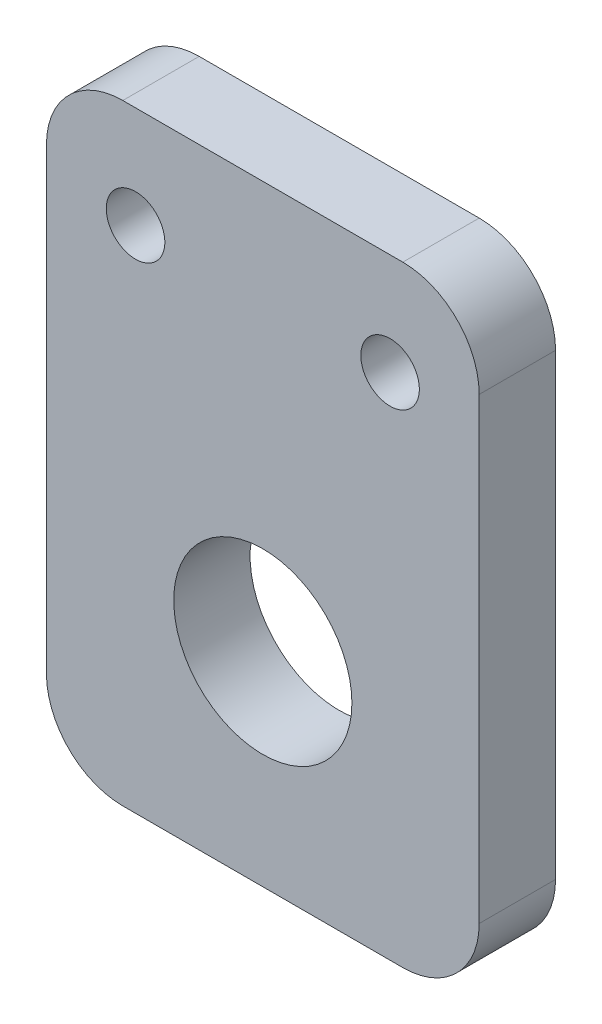
from build123d import *

# Parameters (mm, degrees)
SKETCH_1_W      = 17
SKETCH_1_H      = 24
SKETCH_1_R      = 3.5
SKETCH_1_R_2    = 1.15
EXTRUDE_1_DEPTH = 3
FILLET_1_R      = 3


with BuildPart() as part:
    # 草图1 → 凸台-拉伸1 (new body)
    with BuildSketch(Plane.XY):
        with Locations((0, 12)):
            Rectangle(SKETCH_1_W, SKETCH_1_H)
        with Locations((0, 8)):
            Circle(SKETCH_1_R, mode=Mode.SUBTRACT)
        with Locations((5, 20)):
            Circle(SKETCH_1_R_2, mode=Mode.SUBTRACT)
        with Locations((-5, 20)):
            Circle(SKETCH_1_R_2, mode=Mode.SUBTRACT)
    extrude(amount=EXTRUDE_1_DEPTH)

    # 圆角1
    fillet_1_edges = [part.edges().sort_by_distance(p)[0] for p in [
        (-8.5, 24, 1.5),
        (8.5, 24, 1.5),
        (8.5, 0, 1.5),
        (-8.5, 0, 1.5),
    ]]
    fillet(fillet_1_edges, radius=FILLET_1_R)


solid = part.part
